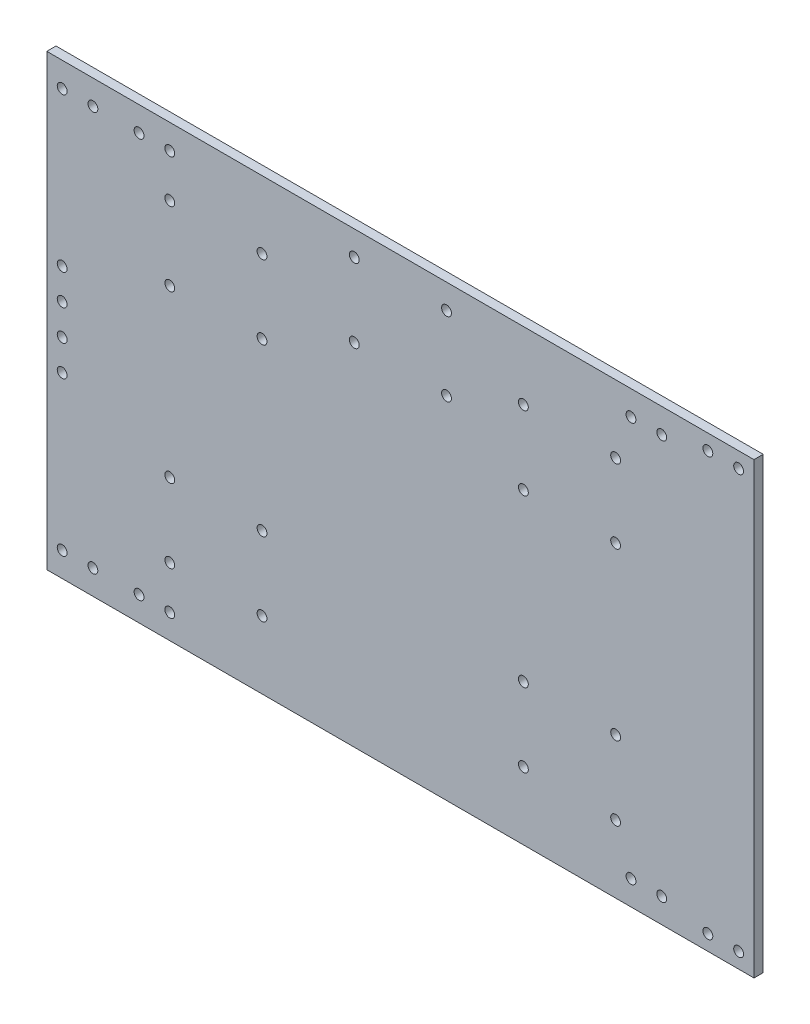
from build123d import *

# Parameters (mm, degrees)
SKETCH_1_W          = 230
SKETCH_1_H          = 146
SKETCH_1_R          = 1.6
EXTRUDE_1_DEPTH     = 3
SKETCH_3_R          = 1.6
EXTRUDE_2_DEPTH     = 3
SKETCH_5_R          = 1.6
CUT_EXTRUDE_1_DEPTH = 4
SKETCH_6_W          = 41.213526348
SKETCH_6_H          = 6.1
CUT_EXTRUDE_2_DEPTH = 4


with BuildPart() as part:
    # 草图1 → 凸台-拉伸1 (new body)
    with BuildSketch(Plane.XY):
        with Locations((-18.384596283, 27.630396061)):
            Rectangle(SKETCH_1_W, SKETCH_1_H)
        with Locations((51.615403717, 0.630396061)):
            Circle(SKETCH_1_R, mode=Mode.SUBTRACT)
        with Locations((51.615403717, -23.369603939)):
            Circle(SKETCH_1_R, mode=Mode.SUBTRACT)
        with Locations((21.615403717, -23.369603939)):
            Circle(SKETCH_1_R, mode=Mode.SUBTRACT)
        with Locations((21.615403717, 0.630396061)):
            Circle(SKETCH_1_R, mode=Mode.SUBTRACT)
        with Locations((51.615403717, 54.630396061)):
            Circle(SKETCH_1_R, mode=Mode.SUBTRACT)
        with Locations((51.615403717, 78.630396061)):
            Circle(SKETCH_1_R, mode=Mode.SUBTRACT)
        with Locations((21.615403717, 78.630396061)):
            Circle(SKETCH_1_R, mode=Mode.SUBTRACT)
        with Locations((21.615403717, 54.630396061)):
            Circle(SKETCH_1_R, mode=Mode.SUBTRACT)
        with Locations((-63.384596283, 0.630396061)):
            Circle(SKETCH_1_R, mode=Mode.SUBTRACT)
        with Locations((-63.384596283, -23.369603939)):
            Circle(SKETCH_1_R, mode=Mode.SUBTRACT)
        with Locations((-93.384596283, -23.369603939)):
            Circle(SKETCH_1_R, mode=Mode.SUBTRACT)
        with Locations((-93.384596283, 0.630396061)):
            Circle(SKETCH_1_R, mode=Mode.SUBTRACT)
        with Locations((-63.384596283, 54.630396061)):
            Circle(SKETCH_1_R, mode=Mode.SUBTRACT)
        with Locations((-63.384596283, 78.630396061)):
            Circle(SKETCH_1_R, mode=Mode.SUBTRACT)
        with Locations((-93.384596283, 78.630396061)):
            Circle(SKETCH_1_R, mode=Mode.SUBTRACT)
        with Locations((-93.384596283, 54.630396061)):
            Circle(SKETCH_1_R, mode=Mode.SUBTRACT)
        with Locations((-3.384596283, 92.630396061)):
            Circle(SKETCH_1_R, mode=Mode.SUBTRACT)
        with Locations((-3.384596283, 68.630396061)):
            Circle(SKETCH_1_R, mode=Mode.SUBTRACT)
        with Locations((-33.384596283, 68.630396061)):
            Circle(SKETCH_1_R, mode=Mode.SUBTRACT)
        with Locations((-33.384596283, 92.630396061)):
            Circle(SKETCH_1_R, mode=Mode.SUBTRACT)
        with Locations((-128.384596283, 22.630396061)):
            Circle(SKETCH_1_R, mode=Mode.SUBTRACT)
        with Locations((-128.384596283, 12.630396061)):
            Circle(SKETCH_1_R, mode=Mode.SUBTRACT)
        with Locations((-128.384596283, 42.630396061)):
            Circle(SKETCH_1_R, mode=Mode.SUBTRACT)
        with Locations((-128.384596283, 32.630396061)):
            Circle(SKETCH_1_R, mode=Mode.SUBTRACT)
        with Locations((91.615403717, -40.369603939)):
            Circle(SKETCH_1_R, mode=Mode.SUBTRACT)
        with Locations((81.615403717, -40.369603939)):
            Circle(SKETCH_1_R, mode=Mode.SUBTRACT)
        with Locations((66.615403717, -37.369603939)):
            Circle(SKETCH_1_R, mode=Mode.SUBTRACT)
        with Locations((56.615403717, -37.369603939)):
            Circle(SKETCH_1_R, mode=Mode.SUBTRACT)
        with Locations((91.615403717, 95.630396061)):
            Circle(SKETCH_1_R, mode=Mode.SUBTRACT)
        with Locations((81.615403717, 95.630396061)):
            Circle(SKETCH_1_R, mode=Mode.SUBTRACT)
        with Locations((56.615403717, 92.630396061)):
            Circle(SKETCH_1_R, mode=Mode.SUBTRACT)
        with Locations((66.615403717, 92.630396061)):
            Circle(SKETCH_1_R, mode=Mode.SUBTRACT)
        with Locations((-103.384596283, -37.369603939)):
            Circle(SKETCH_1_R, mode=Mode.SUBTRACT)
        with Locations((-93.384596283, -37.369603939)):
            Circle(SKETCH_1_R, mode=Mode.SUBTRACT)
        with Locations((-93.384596283, 92.630396061)):
            Circle(SKETCH_1_R, mode=Mode.SUBTRACT)
        with Locations((-103.384596283, 92.630396061)):
            Circle(SKETCH_1_R, mode=Mode.SUBTRACT)
        with Locations((-118.384596283, -37.369603939)):
            Circle(SKETCH_1_R, mode=Mode.SUBTRACT)
        with Locations((-128.384596283, -37.369603939)):
            Circle(SKETCH_1_R, mode=Mode.SUBTRACT)
        with Locations((-118.384596283, 92.630396061)):
            Circle(SKETCH_1_R, mode=Mode.SUBTRACT)
        with Locations((-128.384596283, 92.630396061)):
            Circle(SKETCH_1_R, mode=Mode.SUBTRACT)
    extrude(amount=EXTRUDE_1_DEPTH)

    # 草图3 → 凸台-拉伸2 (add)
    with BuildSketch(Plane.XY.offset(3)):
        Polygon((-92.171069935, -45.369603939), (-78.384596283, -45.369603939), (-22.171069935, -45.369603939), (22.828930065, -45.369603939), (36.615403717, -45.369603939), (96.615403717, -45.369603939), (96.615403717, 100.630396061), (22.828930065, 100.630396061), (-22.171069935, 100.630396061), (-92.171069935, 100.630396061), (-133.384596283, 100.630396061), (-133.384596283, -45.369603939), align=None)
        with Locations((-128.384596283, -37.369603939)):
            Circle(SKETCH_3_R, mode=Mode.SUBTRACT)
        with Locations((-118.384596283, -37.369603939)):
            Circle(SKETCH_3_R, mode=Mode.SUBTRACT)
        with Locations((-103.384596283, -37.369603939)):
            Circle(SKETCH_3_R, mode=Mode.SUBTRACT)
        with Locations((-93.384596283, -37.369603939)):
            Circle(SKETCH_3_R, mode=Mode.SUBTRACT)
        with Locations((-93.384596283, -23.369603939)):
            Circle(SKETCH_3_R, mode=Mode.SUBTRACT)
        with Locations((-128.384596283, 12.630396061)):
            Circle(SKETCH_3_R, mode=Mode.SUBTRACT)
        with Locations((-128.384596283, 22.630396061)):
            Circle(SKETCH_3_R, mode=Mode.SUBTRACT)
        with Locations((-93.384596283, 0.630396061)):
            Circle(SKETCH_3_R, mode=Mode.SUBTRACT)
        with Locations((-63.384596283, -23.369603939)):
            Circle(SKETCH_3_R, mode=Mode.SUBTRACT)
        with BuildLine():
            ThreePointArc((-61.784596283, 0.630396061), (-63.384596283, -0.969603939), (-64.984596283, 0.630396061))
            ThreePointArc((-64.984596283, 0.630396061), (-63.384596283, 2.230396061), (-61.784596283, 0.630396061))
        make_face(mode=Mode.SUBTRACT)
        with Locations((56.615403717, -37.369603939)):
            Circle(SKETCH_3_R, mode=Mode.SUBTRACT)
        with Locations((66.615403717, -37.369603939)):
            Circle(SKETCH_3_R, mode=Mode.SUBTRACT)
        with Locations((81.615403717, -40.369603939)):
            Circle(SKETCH_3_R, mode=Mode.SUBTRACT)
        with Locations((91.615403717, -40.369603939)):
            Circle(SKETCH_3_R, mode=Mode.SUBTRACT)
        with Locations((21.615403717, -23.369603939)):
            Circle(SKETCH_3_R, mode=Mode.SUBTRACT)
        with Locations((21.615403717, 0.630396061)):
            Circle(SKETCH_3_R, mode=Mode.SUBTRACT)
        with Locations((51.615403717, -23.369603939)):
            Circle(SKETCH_3_R, mode=Mode.SUBTRACT)
        with Locations((51.615403717, 0.630396061)):
            Circle(SKETCH_3_R, mode=Mode.SUBTRACT)
        with Locations((-128.384596283, 32.630396061)):
            Circle(SKETCH_3_R, mode=Mode.SUBTRACT)
        with Locations((-128.384596283, 42.630396061)):
            Circle(SKETCH_3_R, mode=Mode.SUBTRACT)
        with Locations((-93.384596283, 54.630396061)):
            Circle(SKETCH_3_R, mode=Mode.SUBTRACT)
        with Locations((-93.384596283, 78.630396061)):
            Circle(SKETCH_3_R, mode=Mode.SUBTRACT)
        with Locations((-63.384596283, 54.630396061)):
            Circle(SKETCH_3_R, mode=Mode.SUBTRACT)
        with Locations((-63.384596283, 78.630396061)):
            Circle(SKETCH_3_R, mode=Mode.SUBTRACT)
        with BuildLine():
            ThreePointArc((-32.135596683, 67.630396061), (-31.874894432, 67.160302015), (-31.784596283, 66.630396061))
            ThreePointArc((-31.784596283, 66.630396061), (-33.914502237, 65.12069421), (-34.633595883, 67.630396061))
            ThreePointArc((-34.633595883, 67.630396061), (-33.914502237, 70.140097913), (-31.784596283, 68.630396061))
            ThreePointArc((-31.784596283, 68.630396061), (-31.874894432, 68.100490107), (-32.135596683, 67.630396061))
        make_face(mode=Mode.SUBTRACT)
        with Locations((-128.384596283, 92.630396061)):
            Circle(SKETCH_3_R, mode=Mode.SUBTRACT)
        with Locations((-118.384596283, 92.630396061)):
            Circle(SKETCH_3_R, mode=Mode.SUBTRACT)
        with Locations((-103.384596283, 92.630396061)):
            Circle(SKETCH_3_R, mode=Mode.SUBTRACT)
        with Locations((-93.384596283, 92.630396061)):
            Circle(SKETCH_3_R, mode=Mode.SUBTRACT)
        with BuildLine():
            ThreePointArc((-32.135596683, 91.630396061), (-31.874894432, 91.160302015), (-31.784596283, 90.630396061))
            ThreePointArc((-31.784596283, 90.630396061), (-33.914502237, 89.12069421), (-34.633595883, 91.630396061))
            ThreePointArc((-34.633595883, 91.630396061), (-33.914502237, 94.140097913), (-31.784596283, 92.630396061))
            ThreePointArc((-31.784596283, 92.630396061), (-31.874894432, 92.100490107), (-32.135596683, 91.630396061))
        make_face(mode=Mode.SUBTRACT)
        with Locations((21.615403717, 54.630396061)):
            Circle(SKETCH_3_R, mode=Mode.SUBTRACT)
        with BuildLine():
            ThreePointArc((-2.135596683, 67.630396061), (-1.874894432, 67.160302015), (-1.784596283, 66.630396061))
            ThreePointArc((-1.784596283, 66.630396061), (-3.914502237, 65.12069421), (-4.633595883, 67.630396061))
            ThreePointArc((-4.633595883, 67.630396061), (-3.914502237, 70.140097913), (-1.784596283, 68.630396061))
            ThreePointArc((-1.784596283, 68.630396061), (-1.874894432, 68.100490107), (-2.135596683, 67.630396061))
        make_face(mode=Mode.SUBTRACT)
        with Locations((21.615403717, 78.630396061)):
            Circle(SKETCH_3_R, mode=Mode.SUBTRACT)
        with Locations((51.615403717, 54.630396061)):
            Circle(SKETCH_3_R, mode=Mode.SUBTRACT)
        with Locations((51.615403717, 78.630396061)):
            Circle(SKETCH_3_R, mode=Mode.SUBTRACT)
        with BuildLine():
            ThreePointArc((-2.135596683, 91.630396061), (-1.874894432, 91.160302015), (-1.784596283, 90.630396061))
            ThreePointArc((-1.784596283, 90.630396061), (-3.914502237, 89.12069421), (-4.633595883, 91.630396061))
            ThreePointArc((-4.633595883, 91.630396061), (-3.914502237, 94.140097913), (-1.784596283, 92.630396061))
            ThreePointArc((-1.784596283, 92.630396061), (-1.874894432, 92.100490107), (-2.135596683, 91.630396061))
        make_face(mode=Mode.SUBTRACT)
        with Locations((56.615403717, 92.630396061)):
            Circle(SKETCH_3_R, mode=Mode.SUBTRACT)
        with Locations((66.615403717, 92.630396061)):
            Circle(SKETCH_3_R, mode=Mode.SUBTRACT)
        with Locations((81.615403717, 95.630396061)):
            Circle(SKETCH_3_R, mode=Mode.SUBTRACT)
        with Locations((91.615403717, 95.630396061)):
            Circle(SKETCH_3_R, mode=Mode.SUBTRACT)
    extrude(amount=-EXTRUDE_2_DEPTH)

    # 草图5 → 切除-拉伸1 (cut, through all)
    with BuildSketch(Plane.XY.offset(3)):
        with Locations((-118.384596283, -67.369603939)):
            Circle(SKETCH_5_R)
        with Locations((-128.384596283, -67.369603939)):
            Circle(SKETCH_5_R)
        with Locations((-128.384596283, 122.630396061)):
            Circle(SKETCH_5_R)
        with Locations((-118.384596283, 122.630396061)):
            Circle(SKETCH_5_R)
    extrude(amount=-CUT_EXTRUDE_1_DEPTH, mode=Mode.SUBTRACT)

    # 草图6 → 切除-拉伸2 (cut, through all)
    with BuildSketch(Plane.XY.offset(3)):
        with Locations((-112.777833109, -78.319603939)):
            Rectangle(SKETCH_6_W, SKETCH_6_H)
        with Locations((-112.777833109, 133.580396061)):
            Rectangle(SKETCH_6_W, SKETCH_6_H)
    extrude(amount=-CUT_EXTRUDE_2_DEPTH, mode=Mode.SUBTRACT)


solid = part.part
